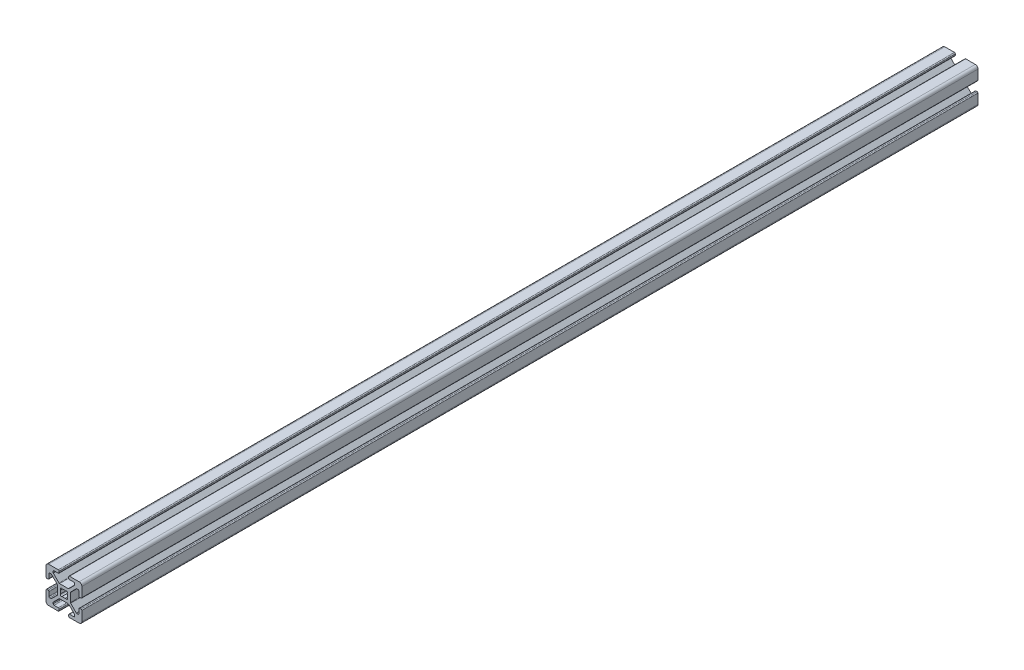
from build123d import *

# Parameters (mm, degrees)
BOSS_EXTRUDE1_DEPTH = 500


with BuildPart() as part:
    # Sketch1 → Boss-Extrude1 (new body)
    with BuildSketch(Plane.XY):
        with BuildLine():
            Line((-2.746356642, -3.807016814), (-5.847983186, -6.908643358))
            ThreePointArc((-5.847983186, -6.908643358), (-5.956791575, -7.07148662), (-5.995, -7.263573344))
            Line((-5.995, -7.263573344), (-5.995, -7.858053199))
            ThreePointArc((-5.995, -7.858053199), (-5.847983186, -8.212983186), (-5.493053199, -8.36))
            Line((-5.493053199, -8.36), (-3.131946801, -8.36))
            ThreePointArc((-3.131946801, -8.36), (-2.777016814, -8.507016814), (-2.63, -8.861946801))
            Line((-2.63, -8.861946801), (-2.63, -9.498053199))
            ThreePointArc((-2.63, -9.498053199), (-2.777016814, -9.852983186), (-3.131946801, -10))
            Line((-3.131946801, -10), (-8.5, -10))
            ThreePointArc((-8.5, -10), (-9.560660172, -9.560660172), (-10, -8.5))
            Line((-10, -8.5), (-10, -3.131946801))
            ThreePointArc((-10, -3.131946801), (-9.852983186, -2.777016814), (-9.498053199, -2.63))
            Line((-9.498053199, -2.63), (-8.861946801, -2.63))
            ThreePointArc((-8.861946801, -2.63), (-8.507016814, -2.777016814), (-8.36, -3.131946801))
            Line((-8.36, -3.131946801), (-8.36, -5.493053199))
            ThreePointArc((-8.36, -5.493053199), (-8.212983186, -5.847983186), (-7.858053199, -5.995))
            Line((-7.858053199, -5.995), (-7.263573344, -5.995))
            ThreePointArc((-7.263573344, -5.995), (-7.07148662, -5.956791575), (-6.908643358, -5.847983186))
            Line((-6.908643358, -5.847983186), (-3.807016814, -2.746356642))
            ThreePointArc((-3.807016814, -2.746356642), (-3.698208425, -2.58351338), (-3.66, -2.391426656))
            Line((-3.66, -2.391426656), (-3.66, 2.391426656))
            ThreePointArc((-3.66, 2.391426656), (-3.698208425, 2.58351338), (-3.807016814, 2.746356642))
            Line((-3.807016814, 2.746356642), (-6.908643358, 5.847983186))
            ThreePointArc((-6.908643358, 5.847983186), (-7.07148662, 5.956791575), (-7.263573344, 5.995))
            Line((-7.263573344, 5.995), (-7.858053199, 5.995))
            ThreePointArc((-7.858053199, 5.995), (-8.212983186, 5.847983186), (-8.36, 5.493053199))
            Line((-8.36, 5.493053199), (-8.36, 3.131946801))
            ThreePointArc((-8.36, 3.131946801), (-8.507016814, 2.777016814), (-8.861946801, 2.63))
            Line((-8.861946801, 2.63), (-9.498053199, 2.63))
            ThreePointArc((-9.498053199, 2.63), (-9.852983186, 2.777016814), (-10, 3.131946801))
            Line((-10, 3.131946801), (-10, 8.5))
            ThreePointArc((-10, 8.5), (-9.560660172, 9.560660172), (-8.5, 10))
            Line((-8.5, 10), (-3.131946801, 10))
            ThreePointArc((-3.131946801, 10), (-2.777016814, 9.852983186), (-2.63, 9.498053199))
            Line((-2.63, 9.498053199), (-2.63, 8.861946801))
            ThreePointArc((-2.63, 8.861946801), (-2.777016814, 8.507016814), (-3.131946801, 8.36))
            Line((-3.131946801, 8.36), (-5.493053199, 8.36))
            ThreePointArc((-5.493053199, 8.36), (-5.847983186, 8.212983186), (-5.995, 7.858053199))
            Line((-5.995, 7.858053199), (-5.995, 7.263573344))
            ThreePointArc((-5.995, 7.263573344), (-5.956791575, 7.07148662), (-5.847983186, 6.908643358))
            Line((-5.847983186, 6.908643358), (-2.746356642, 3.807016814))
            ThreePointArc((-2.746356642, 3.807016814), (-2.58351338, 3.698208425), (-2.391426656, 3.66))
            Line((-2.391426656, 3.66), (2.391426656, 3.66))
            ThreePointArc((2.391426656, 3.66), (2.58351338, 3.698208425), (2.746356642, 3.807016814))
            Line((2.746356642, 3.807016814), (5.847983186, 6.908643358))
            ThreePointArc((5.847983186, 6.908643358), (5.956791575, 7.07148662), (5.995, 7.263573344))
            Line((5.995, 7.263573344), (5.995, 7.858053199))
            ThreePointArc((5.995, 7.858053199), (5.847983186, 8.212983186), (5.493053199, 8.36))
            Line((5.493053199, 8.36), (3.131946801, 8.36))
            ThreePointArc((3.131946801, 8.36), (2.777016814, 8.507016814), (2.63, 8.861946801))
            Line((2.63, 8.861946801), (2.63, 9.498053199))
            ThreePointArc((2.63, 9.498053199), (2.777016814, 9.852983186), (3.131946801, 10))
            Line((3.131946801, 10), (8.5, 10))
            ThreePointArc((8.5, 10), (9.560660172, 9.560660172), (10, 8.5))
            Line((10, 8.5), (10, 3.131946801))
            ThreePointArc((10, 3.131946801), (9.852983186, 2.777016814), (9.498053199, 2.63))
            Line((9.498053199, 2.63), (8.861946801, 2.63))
            ThreePointArc((8.861946801, 2.63), (8.507016814, 2.777016814), (8.36, 3.131946801))
            Line((8.36, 3.131946801), (8.36, 5.493053199))
            ThreePointArc((8.36, 5.493053199), (8.212983186, 5.847983186), (7.858053199, 5.995))
            Line((7.858053199, 5.995), (7.263573344, 5.995))
            ThreePointArc((7.263573344, 5.995), (7.07148662, 5.956791575), (6.908643358, 5.847983186))
            Line((6.908643358, 5.847983186), (3.807016814, 2.746356642))
            ThreePointArc((3.807016814, 2.746356642), (3.698208425, 2.58351338), (3.66, 2.391426656))
            Line((3.66, 2.391426656), (3.66, -2.391426656))
            ThreePointArc((3.66, -2.391426656), (3.698208425, -2.58351338), (3.807016814, -2.746356642))
            Line((3.807016814, -2.746356642), (6.908643358, -5.847983186))
            ThreePointArc((6.908643358, -5.847983186), (7.07148662, -5.956791575), (7.263573344, -5.995))
            Line((7.263573344, -5.995), (7.858053199, -5.995))
            ThreePointArc((7.858053199, -5.995), (8.212983186, -5.847983186), (8.36, -5.493053199))
            Line((8.36, -5.493053199), (8.36, -3.131946801))
            ThreePointArc((8.36, -3.131946801), (8.507016814, -2.777016814), (8.861946801, -2.63))
            Line((8.861946801, -2.63), (9.498053199, -2.63))
            ThreePointArc((9.498053199, -2.63), (9.852983186, -2.777016814), (10, -3.131946801))
            Line((10, -3.131946801), (10, -8.5))
            ThreePointArc((10, -8.5), (9.560660172, -9.560660172), (8.5, -10))
            Line((8.5, -10), (3.131946801, -10))
            ThreePointArc((3.131946801, -10), (2.777016814, -9.852983186), (2.63, -9.498053199))
            Line((2.63, -9.498053199), (2.63, -8.861946801))
            ThreePointArc((2.63, -8.861946801), (2.777016814, -8.507016814), (3.131946801, -8.36))
            Line((3.131946801, -8.36), (5.493053199, -8.36))
            ThreePointArc((5.493053199, -8.36), (5.847983186, -8.212983186), (5.995, -7.858053199))
            Line((5.995, -7.858053199), (5.995, -7.263573344))
            ThreePointArc((5.995, -7.263573344), (5.956791575, -7.07148662), (5.847983186, -6.908643358))
            Line((5.847983186, -6.908643358), (2.746356642, -3.807016814))
            ThreePointArc((2.746356642, -3.807016814), (2.58351338, -3.698208425), (2.391426656, -3.66))
            Line((2.391426656, -3.66), (-2.391426656, -3.66))
            ThreePointArc((-2.391426656, -3.66), (-2.58351338, -3.698208425), (-2.746356642, -3.807016814))
        make_face()
        with BuildLine():
            ThreePointArc((-1.767678053, 0.935582333), (-2, 0), (-1.767678053, -0.935582333))
            ThreePointArc((-1.767678053, -0.935582333), (-1.834942097, -1.834942097), (-0.935582333, -1.767678053))
            ThreePointArc((-0.935582333, -1.767678053), (0, -2), (0.935582333, -1.767678053))
            ThreePointArc((0.935582333, -1.767678053), (1.834942097, -1.834942097), (1.767678053, -0.935582333))
            ThreePointArc((1.767678053, -0.935582333), (2, 0), (1.767678053, 0.935582333))
            ThreePointArc((1.767678053, 0.935582333), (1.834942097, 1.834942097), (0.935582333, 1.767678053))
            ThreePointArc((0.935582333, 1.767678053), (0, 2), (-0.935582333, 1.767678053))
            ThreePointArc((-0.935582333, 1.767678053), (-1.834942097, 1.834942097), (-1.767678053, 0.935582333))
        make_face(mode=Mode.SUBTRACT)
    extrude(amount=BOSS_EXTRUDE1_DEPTH)


solid = part.part
